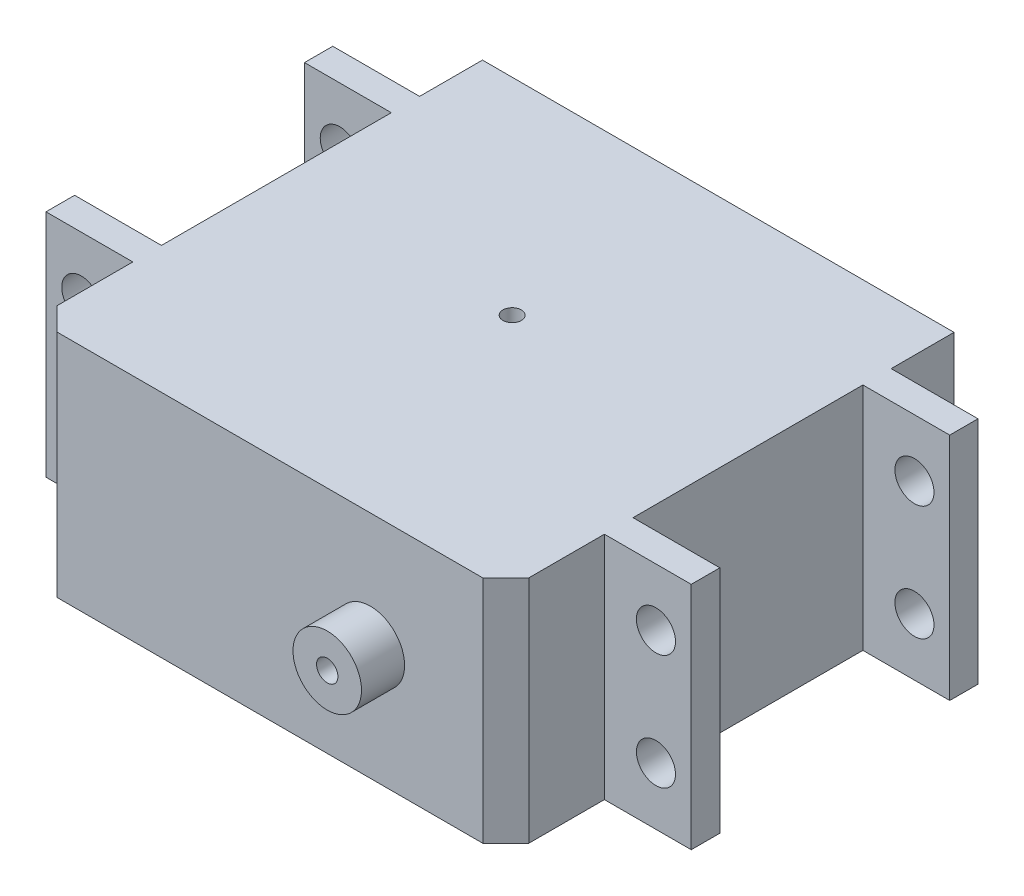
from build123d import *

# Parameters (mm, degrees)
SKETCH1_W                        = 56.14
SKETCH1_H                        = 20
BOSS_EXTRUDE1_DEPTH              = 2.49
M3_CLEARANCE_HOLE1_D             = 3.4
M3_CLEARANCE_HOLE1_DEPTH         = 19
M3_CLEARANCE_HOLE1_TIP           = 1.021463052
SKETCH4_W                        = 41.03
SKETCH4_H                        = 20
BOSS_EXTRUDE2_DEPTH              = 8.58
SKETCH5_R                        = 2.98
SKETCH5_R_2                      = 0.928997072
BOSS_EXTRUDE3_DEPTH              = 3.75
SKETCH6_W                        = 8
SKETCH6_H                        = 20
BOSS_EXTRUDE4_DEPTH              = 20
BOSS_EXTRUDE4_2_DEPTH            = 20
SKETCH7_W                        = 41.03
SKETCH7_H                        = 20
BOSS_EXTRUDE5_DEPTH              = 20
SKETCH8_W                        = 56.14
SKETCH8_H                        = 20
BOSS_EXTRUDE6_DEPTH              = 2.46
SKETCH12_W                       = 1.7
SKETCH12_H                       = 24.95
M3_CLEARANCE_HOLE2_AT_2_COUNT    = 2
M3_CLEARANCE_HOLE2_AT_2_PITCH    = 10
M3_CLEARANCE_HOLE2_AT_3_COUNT    = 2
M3_CLEARANCE_HOLE2_AT_3_PITCH    = 50
M3_CLEARANCE_HOLE2_AT_4_COUNT    = 2
M3_CLEARANCE_HOLE2_AT_4_PITCH    = 50.990195136
SKETCH13_W                       = 41.03
SKETCH13_H                       = 20
BOSS_EXTRUDE7_DEPTH              = 39
SKETCH14_R                       = 4
SKETCH14_R_2                     = 1.25
BOSS_EXTRUDE8_DEPTH              = 5.37
SKETCH16_W                       = 0.8
SKETCH16_H                       = 20.00005
TAP_DRILL_FOR_M2_TAP1_AT_2_COUNT = 2
TAP_DRILL_FOR_M2_TAP1_AT_2_PITCH = 25.495097568
TAP_DRILL_FOR_M2_TAP1_AT_3_COUNT = 2
TAP_DRILL_FOR_M2_TAP1_AT_3_PITCH = 10
TAP_DRILL_FOR_M2_TAP1_AT_4_COUNT = 2
TAP_DRILL_FOR_M2_TAP1_AT_4_PITCH = 50
TAP_DRILL_FOR_M2_TAP1_AT_5_COUNT = 2
TAP_DRILL_FOR_M2_TAP1_AT_5_PITCH = 50.990195136
CHAMFER1_SIZE                    = 2
SKETCH19_R                       = 6.18
SKETCH19_R_2                     = 4
BOSS_EXTRUDE10_DEPTH             = 2.12
SKETCH21_W                       = 8
SKETCH21_H                       = 7
CUT_EXTRUDE1_DEPTH               = 28
SKETCH22_W                       = 20
SKETCH22_H                       = 20
CUT_EXTRUDE2_DEPTH               = 8.235
SKETCH23_W                       = 20
SKETCH23_H                       = 20
CUT_EXTRUDE3_DEPTH               = 8.235


with BuildPart() as part:
    # Sketch1 → Boss-Extrude1 (new body)
    with BuildSketch(Plane.XY):
        Rectangle(SKETCH1_W, SKETCH1_H)
    extrude(amount=BOSS_EXTRUDE1_DEPTH)

    # M3 Clearance Hole1
    with Locations(Plane.XY.offset(2.49)):
        with Locations((25, 5), (0, 0), (-25, 5), (-25, -5), (25, -5)):
            Hole(M3_CLEARANCE_HOLE1_D / 2, depth=M3_CLEARANCE_HOLE1_DEPTH)
            with Locations((0, 0, -(M3_CLEARANCE_HOLE1_DEPTH + M3_CLEARANCE_HOLE1_TIP / 2))):  # 118° drill point
                Cone(0, M3_CLEARANCE_HOLE1_D / 2, M3_CLEARANCE_HOLE1_TIP, mode=Mode.SUBTRACT)

    # Sketch4 → Boss-Extrude2 (add)
    with BuildSketch(Plane.XY.offset(2.49)):
        Rectangle(SKETCH4_W, SKETCH4_H)
    extrude(amount=BOSS_EXTRUDE2_DEPTH)

    # Sketch5 → Boss-Extrude3 (add)
    with BuildSketch(Plane.XY.offset(11.07)):
        with Locations((8.73, 0)):
            Circle(SKETCH5_R)
        with Locations((8.73, 0)):
            Circle(SKETCH5_R_2, mode=Mode.SUBTRACT)
    extrude(amount=BOSS_EXTRUDE3_DEPTH)

    # Sketch7 → Boss-Extrude5 (add)
    with BuildSketch(Plane(origin=(0, 0, 0), x_dir=(-1, 0, 0), z_dir=(0, 0, -1))):
        Rectangle(SKETCH7_W, SKETCH7_H)
    extrude(amount=BOSS_EXTRUDE5_DEPTH)

    # Sketch8 → Boss-Extrude6 (add)
    with BuildSketch(Plane(origin=(0, 0, -20), x_dir=(-1, 0, 0), z_dir=(0, 0, -1))):
        Rectangle(SKETCH8_W, SKETCH8_H)
    extrude(amount=BOSS_EXTRUDE6_DEPTH)


with BuildPart() as body_2:
    # Sketch6 → Boss-Extrude4 (new body)
    with BuildSketch(Plane(origin=(0, 0, 0), x_dir=(-1, 0, 0), z_dir=(0, 0, -1))):
        with Locations((-24.75, 0)):
            Rectangle(SKETCH6_W, SKETCH6_H)
    extrude(amount=BOSS_EXTRUDE4_DEPTH)


with BuildPart() as body_3:
    # Sketch6 → Boss-Extrude4 2 (new body)
    with BuildSketch(Plane(origin=(0, 0, 0), x_dir=(-1, 0, 0), z_dir=(0, 0, -1))):
        with Locations((24.75, 0)):
            Rectangle(SKETCH6_W, SKETCH6_H)
    extrude(amount=BOSS_EXTRUDE4_2_DEPTH)


with BuildPart() as m3_clearance_hole2_tool:
    # Sketch12 → M3 Clearance Hole2 (revolve)
    with BuildSketch(Plane(origin=(25, 5, 2.49), x_dir=(0, -1, 0), z_dir=(1, 0, 0))):
        with Locations((0.85, 12.475)):
            Rectangle(SKETCH12_W, SKETCH12_H)
    m3_clearance_hole2 = revolve(axis=Axis((25, 5, 8.84), (0, 0, -1)))


with BuildPart() as part_1:
    add(part.part)

    # M3 Clearance Hole2: cut by m3_clearance_hole2_tool
    add(m3_clearance_hole2_tool.part, mode=Mode.SUBTRACT)


with BuildPart() as body_2_1:
    add(body_2.part)

    # M3 Clearance Hole2: cut by m3_clearance_hole2_tool
    add(m3_clearance_hole2_tool.part, mode=Mode.SUBTRACT)


with BuildPart() as m3_clearance_hole2_at_2_tool:
    # M3 Clearance Hole2 at 2: M3 Clearance Hole2 ×2
    with Locations(*[(0, -i * M3_CLEARANCE_HOLE2_AT_2_PITCH, 0) for i in range(1, M3_CLEARANCE_HOLE2_AT_2_COUNT)]):
        add(m3_clearance_hole2)


with BuildPart() as part_2:
    add(part_1.part)

    # M3 Clearance Hole2 at 2: cut by m3_clearance_hole2_at_2_tool
    add(m3_clearance_hole2_at_2_tool.part, mode=Mode.SUBTRACT)


with BuildPart() as body_2_2:
    add(body_2_1.part)

    # M3 Clearance Hole2 at 2: cut by m3_clearance_hole2_at_2_tool
    add(m3_clearance_hole2_at_2_tool.part, mode=Mode.SUBTRACT)


with BuildPart() as m3_clearance_hole2_at_3_tool:
    # M3 Clearance Hole2 at 3: M3 Clearance Hole2 ×2
    with Locations(*[(-i * M3_CLEARANCE_HOLE2_AT_3_PITCH, 0, 0) for i in range(1, M3_CLEARANCE_HOLE2_AT_3_COUNT)]):
        add(m3_clearance_hole2)


with BuildPart() as part_3:
    add(part_2.part)

    # M3 Clearance Hole2 at 3: cut by m3_clearance_hole2_at_3_tool
    add(m3_clearance_hole2_at_3_tool.part, mode=Mode.SUBTRACT)


with BuildPart() as body_3_1:
    add(body_3.part)

    # M3 Clearance Hole2 at 3: cut by m3_clearance_hole2_at_3_tool
    add(m3_clearance_hole2_at_3_tool.part, mode=Mode.SUBTRACT)


with BuildPart() as m3_clearance_hole2_at_4_tool:
    # M3 Clearance Hole2 at 4: M3 Clearance Hole2 ×2
    with Locations(*[Vector(-0.9805806756909201, -0.19611613513818418, 0) * (i * M3_CLEARANCE_HOLE2_AT_4_PITCH) for i in range(1, M3_CLEARANCE_HOLE2_AT_4_COUNT)]):
        add(m3_clearance_hole2)


with BuildPart() as part_4:
    add(part_3.part)

    # M3 Clearance Hole2 at 4: cut by m3_clearance_hole2_at_4_tool
    add(m3_clearance_hole2_at_4_tool.part, mode=Mode.SUBTRACT)

    # Sketch13 → Boss-Extrude7 (add)
    with BuildSketch(Plane.XY.offset(11.07)):
        Rectangle(SKETCH13_W, SKETCH13_H)
    extrude(amount=-BOSS_EXTRUDE7_DEPTH)

    # Sketch14 → Boss-Extrude8 (add)
    with BuildSketch(Plane(origin=(0, 0, -27.93), x_dir=(-1, 0, 0), z_dir=(0, 0, -1))):
        with Locations(Location((-8.73, 0, 0), (0, 0, 180))):
            Circle(SKETCH14_R)
        with Locations(Location((-8.73, 0, 0), (0, 0, 180))):
            Circle(SKETCH14_R_2, mode=Mode.SUBTRACT)
    extrude(amount=BOSS_EXTRUDE8_DEPTH)


with BuildPart() as body_3_2:
    add(body_3_1.part)

    # M3 Clearance Hole2 at 4: cut by m3_clearance_hole2_at_4_tool
    add(m3_clearance_hole2_at_4_tool.part, mode=Mode.SUBTRACT)

    # Sketch16 → Tap Drill for M2 Tap1 (revolve, cut)
    with BuildSketch(Plane(origin=(-25, -10, -5), x_dir=(0, 0, -1), z_dir=(1, 0, 0))):
        with Locations((0.4, 10.000025)):
            Rectangle(SKETCH16_W, SKETCH16_H)
    tap_drill_for_m2_tap1 = revolve(axis=Axis((-25, -16.35, -5), (0, 1, 0)), mode=Mode.SUBTRACT)

    # Tap Drill for M2 Tap1 at 3: Tap Drill for M2 Tap1 ×2
    with Locations(*[(0, 0, -i * TAP_DRILL_FOR_M2_TAP1_AT_3_PITCH) for i in range(1, TAP_DRILL_FOR_M2_TAP1_AT_3_COUNT)]):
        add(tap_drill_for_m2_tap1, mode=Mode.SUBTRACT)


with BuildPart() as part_5:
    add(part_4.part)

    # Tap Drill for M2 Tap1 at 2: Tap Drill for M2 Tap1 ×2
    with Locations(*[Vector(0.9805806756909201, 0, -0.1961161351381842) * (i * TAP_DRILL_FOR_M2_TAP1_AT_2_PITCH) for i in range(1, TAP_DRILL_FOR_M2_TAP1_AT_2_COUNT)]):
        add(tap_drill_for_m2_tap1, mode=Mode.SUBTRACT)

    # Chamfer1
    chamfer1_edges = [part_5.edges().sort_by_distance(p)[0] for p in [
        (-20.515, 0, 11.07),
        (20.515, 0, 11.07),
    ]]
    chamfer(chamfer1_edges, length=CHAMFER1_SIZE)

    # Sketch19 → Boss-Extrude10 (add)
    with BuildSketch(Plane(origin=(0, 0, -27.93), x_dir=(-1, 0, 0), z_dir=(0, 0, -1))):
        with Locations(Location((-8.73, 0, 0), (0, 0, 180))):
            Circle(SKETCH19_R)
        with Locations(Location((-8.73, 0, 0), (0, 0, 180))):
            Circle(SKETCH19_R_2, mode=Mode.SUBTRACT)
    extrude(amount=BOSS_EXTRUDE10_DEPTH)


with BuildPart() as body_2_3:
    add(body_2_2.part)

    # Tap Drill for M2 Tap1 at 4: Tap Drill for M2 Tap1 ×2
    with Locations(*[(i * TAP_DRILL_FOR_M2_TAP1_AT_4_PITCH, 0, 0) for i in range(1, TAP_DRILL_FOR_M2_TAP1_AT_4_COUNT)]):
        add(tap_drill_for_m2_tap1, mode=Mode.SUBTRACT)

    # Tap Drill for M2 Tap1 at 5: Tap Drill for M2 Tap1 ×2
    with Locations(*[Vector(0.9805806756909202, 0, -0.19611613513818407) * (i * TAP_DRILL_FOR_M2_TAP1_AT_5_PITCH) for i in range(1, TAP_DRILL_FOR_M2_TAP1_AT_5_COUNT)]):
        add(tap_drill_for_m2_tap1, mode=Mode.SUBTRACT)


with BuildPart() as cut_extrude1_tool:
    # Sketch21 → Cut-Extrude1 (new body)
    with BuildSketch(Plane(origin=(0, 10, 0), x_dir=(1, 0, 0), z_dir=(0, 1, 0))):
        with Locations((-24.75, 10)):
            Rectangle(SKETCH21_W, SKETCH21_H)
        with Locations((24.75, 10)):
            Rectangle(SKETCH21_W, SKETCH21_H)
    extrude(amount=-CUT_EXTRUDE1_DEPTH)


with BuildPart() as body_2_4:
    add(body_2_3.part)

    # Cut-Extrude1: cut by cut_extrude1_tool
    add(cut_extrude1_tool.part, mode=Mode.SUBTRACT)


with BuildPart() as body_3_3:
    add(body_3_2.part)

    # Cut-Extrude1: cut by cut_extrude1_tool
    add(cut_extrude1_tool.part, mode=Mode.SUBTRACT)


with BuildPart() as cut_extrude1_piece_1:
    # of the separate pieces the step leaves, piece 1, a body of its own (cut_extrude1_pieces)
    add(body_2_4.part.solids().sort_by_distance((20.75, 10, 0))[0])


with BuildPart() as cut_extrude1_piece_2:
    # of the separate pieces the step leaves, piece 2, a body of its own (cut_extrude1_pieces)
    add(body_2_4.part.solids().sort_by_distance((20.75, 10, -13.5))[0])


with BuildPart() as cut_extrude1_piece_1_of_body_3:
    # of the separate pieces the step leaves, piece 1, a body of its own (cut_extrude1_pieces_of_body_3)
    add(body_3_3.part.solids().sort_by_distance((-28.75, 10, 0))[0])


with BuildPart() as cut_extrude1_piece_2_of_body_3:
    # of the separate pieces the step leaves, piece 2, a body of its own (cut_extrude1_pieces_of_body_3)
    add(body_3_3.part.solids().sort_by_distance((-28.75, 10, -13.5))[0])


with BuildPart() as cut_extrude2_tool:
    # Sketch22 → Cut-Extrude2 (new body)
    with BuildSketch(Plane.ZY.offset(28.75)):
        with Locations((-10, 0)):
            Rectangle(SKETCH22_W, SKETCH22_H)
    extrude(amount=-CUT_EXTRUDE2_DEPTH)


with BuildPart() as cut_extrude1_piece_1_of_body_3_1:
    add(cut_extrude1_piece_1_of_body_3.part)

    # Cut-Extrude2: cut by cut_extrude2_tool
    add(cut_extrude2_tool.part, mode=Mode.SUBTRACT)


with BuildPart() as cut_extrude1_piece_2_of_body_3_1:
    add(cut_extrude1_piece_2_of_body_3.part)

    # Cut-Extrude2: cut by cut_extrude2_tool
    add(cut_extrude2_tool.part, mode=Mode.SUBTRACT)


with BuildPart() as cut_extrude3_tool:
    # Sketch23 → Cut-Extrude3 (new body)
    with BuildSketch(Plane(origin=(28.75, 0, 0), x_dir=(0, 0, -1), z_dir=(1, 0, 0))):
        with Locations((10, 0)):
            Rectangle(SKETCH23_W, SKETCH23_H)
    extrude(amount=-CUT_EXTRUDE3_DEPTH)


with BuildPart() as cut_extrude1_piece_1_1:
    add(cut_extrude1_piece_1.part)

    # Cut-Extrude3: cut by cut_extrude3_tool
    add(cut_extrude3_tool.part, mode=Mode.SUBTRACT)


with BuildPart() as cut_extrude1_piece_2_1:
    add(cut_extrude1_piece_2.part)

    # Cut-Extrude3: cut by cut_extrude3_tool
    add(cut_extrude3_tool.part, mode=Mode.SUBTRACT)


solid = part_5.part
